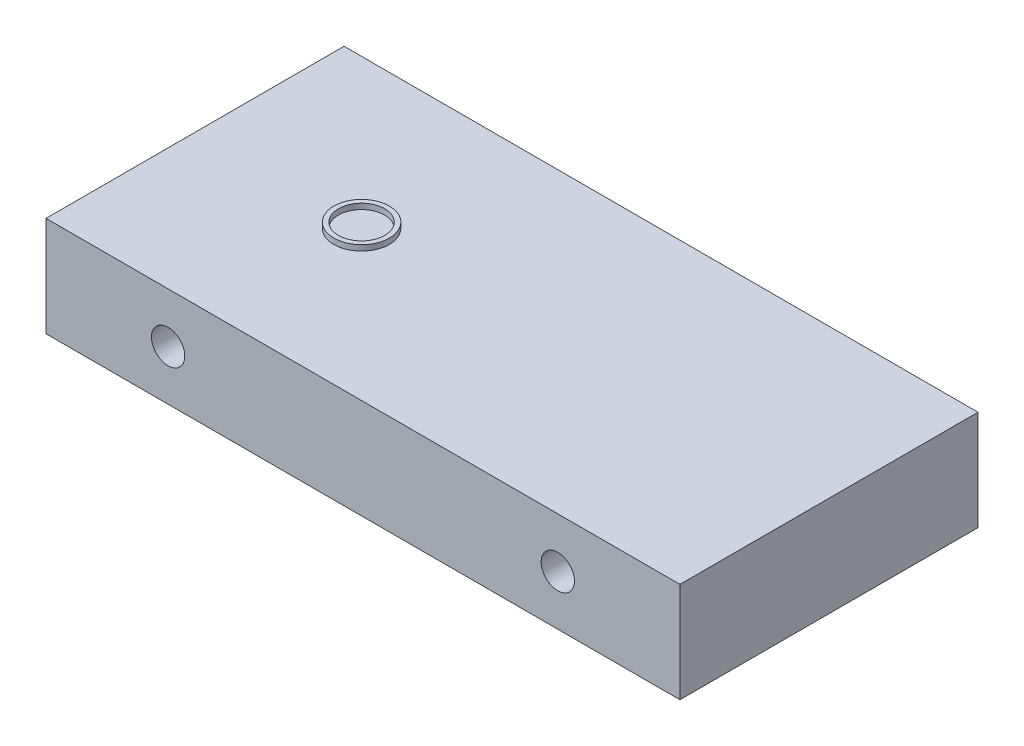
from build123d import *

# Parameters (mm, degrees)
SKETCH1_W           = 342.543491
SKETCH1_H           = 161.067786
BOSS_EXTRUDE1_DEPTH = 54
SKETCH3_R           = 9
CUT_EXTRUDE1_DEPTH  = 340.02
SKETCH4_R           = 15
SKETCH4_R_2         = 12.5
BOSS_EXTRUDE2_DEPTH = 3


with BuildPart() as part:
    # Sketch1 → Boss-Extrude1 (new body)
    with BuildSketch(Plane(origin=(0, 0, 0), x_dir=(1, 0, 0), z_dir=(0, 1, 0))):
        Rectangle(SKETCH1_W, SKETCH1_H)
    extrude(amount=BOSS_EXTRUDE1_DEPTH)

    # Sketch3 → Cut-Extrude1 (cut)
    with BuildSketch(Plane(origin=(0, 0, -80.533893), x_dir=(-1, 0, 0), z_dir=(0, 0, -1))):
        with Locations((-105.2849429, 27)):
            Circle(SKETCH3_R)
        with Locations((105.2849429, 27)):
            Circle(SKETCH3_R)
    extrude(amount=-CUT_EXTRUDE1_DEPTH, mode=Mode.SUBTRACT)

    # Sketch4 → Boss-Extrude2 (add)
    with BuildSketch(Plane(origin=(0, 54, 0), x_dir=(1, 0, 0), z_dir=(0, 1, 0))):
        with Locations((-81.2717455, 0)):
            Circle(SKETCH4_R)
        with Locations((-81.2717455, 0)):
            Circle(SKETCH4_R_2, mode=Mode.SUBTRACT)
    extrude(amount=BOSS_EXTRUDE2_DEPTH)


solid = part.part
